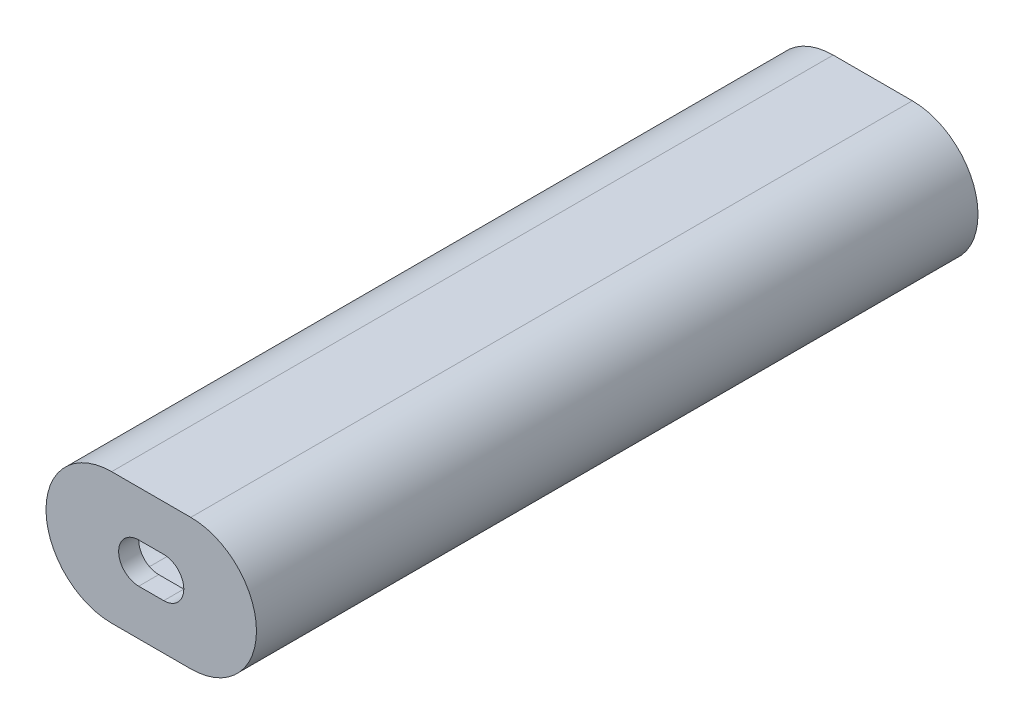
from build123d import *

# Parameters (mm, degrees)
BOSS_EXTRUDE1_DEPTH = 177.8
BOSS_EXTRUDE2_DEPTH = 5.08
SKETCH5_R           = 3.683
CUT_EXTRUDE2_DEPTH  = 4.191
SKETCH6_R           = 2.286
CUT_EXTRUDE3_DEPTH  = 6.731
CUT_EXTRUDE5_DEPTH  = 5.08


with BuildPart() as part:
    # Sketch1 → Boss-Extrude1 (new body)
    with BuildSketch(Plane.XY):
        with BuildLine():
            ThreePointArc((-24.13, 0), (-20.74503307, 8.17203307), (-12.573, 11.557))
            Line((-12.573, 11.557), (12.573, 11.557))
            ThreePointArc((12.573, 11.557), (20.74503307, 8.17203307), (24.13, 0))
            Line((24.13, 0), (26.67, 0))
            ThreePointArc((26.67, 0), (21.797135519, 11.764135519), (10.033, 16.637))
            Line((10.033, 16.637), (-10.033, 16.637))
            ThreePointArc((-10.033, 16.637), (-21.797135519, 11.764135519), (-26.67, 0))
            Line((-26.67, 0), (-24.13, 0))
        make_face()
        with BuildLine():
            ThreePointArc((-12.573, -11.557), (-20.74503307, -8.17203307), (-24.13, 0))
            Line((-24.13, 0), (-26.67, 0))
            ThreePointArc((-26.67, 0), (-21.797135519, -11.764135519), (-10.033, -16.637))
            Line((-10.033, -16.637), (10.033, -16.637))
            ThreePointArc((10.033, -16.637), (21.797135519, -11.764135519), (26.67, 0))
            Line((26.67, 0), (24.13, 0))
            ThreePointArc((24.13, 0), (20.74503307, -8.17203307), (12.573, -11.557))
            Line((12.573, -11.557), (-12.573, -11.557))
        make_face()
    extrude(amount=-BOSS_EXTRUDE1_DEPTH)

    # Sketch3 → Boss-Extrude2 (add)
    with BuildSketch(Plane.XY):
        with BuildLine():
            Line((-10.033, 16.637), (10.033, 16.637))
            ThreePointArc((10.033, 16.637), (26.67, 0), (10.033, -16.637))
            Line((10.033, -16.637), (-10.033, -16.637))
            ThreePointArc((-10.033, -16.637), (-26.67, 0), (-10.033, 16.637))
        make_face()
    extrude(amount=BOSS_EXTRUDE2_DEPTH)

    # Sketch5 → Cut-Extrude2 (cut)
    with BuildSketch(Plane(origin=(0, -11.557, 0), x_dir=(1, 0, 0), z_dir=(0, 1, 0))):
        with Locations((0, 119.888)):
            Circle(SKETCH5_R)
        with Locations((0, 52.832)):
            Circle(SKETCH5_R)
    extrude(amount=-CUT_EXTRUDE2_DEPTH, mode=Mode.SUBTRACT)

    # Sketch6 → Cut-Extrude3 (cut)
    with BuildSketch(Plane(origin=(0, -11.557, 0), x_dir=(1, 0, 0), z_dir=(0, 1, 0))):
        with Locations((0, 119.888)):
            Circle(SKETCH6_R)
        with Locations((0, 52.832)):
            Circle(SKETCH6_R)
    extrude(amount=-CUT_EXTRUDE3_DEPTH, mode=Mode.SUBTRACT)

    # Sketch7 → Cut-Extrude5 (cut)
    with BuildSketch(Plane.XY.offset(5.08)):
        with BuildLine():
            Line((-3.175, 5.08), (3.175, 5.08))
            ThreePointArc((3.175, 5.08), (8.255, 0), (3.175, -5.08))
            Line((3.175, -5.08), (-3.175, -5.08))
            ThreePointArc((-3.175, -5.08), (-8.255, 0), (-3.175, 5.08))
        make_face()
    extrude(amount=-CUT_EXTRUDE5_DEPTH, mode=Mode.SUBTRACT)


solid = part.part
